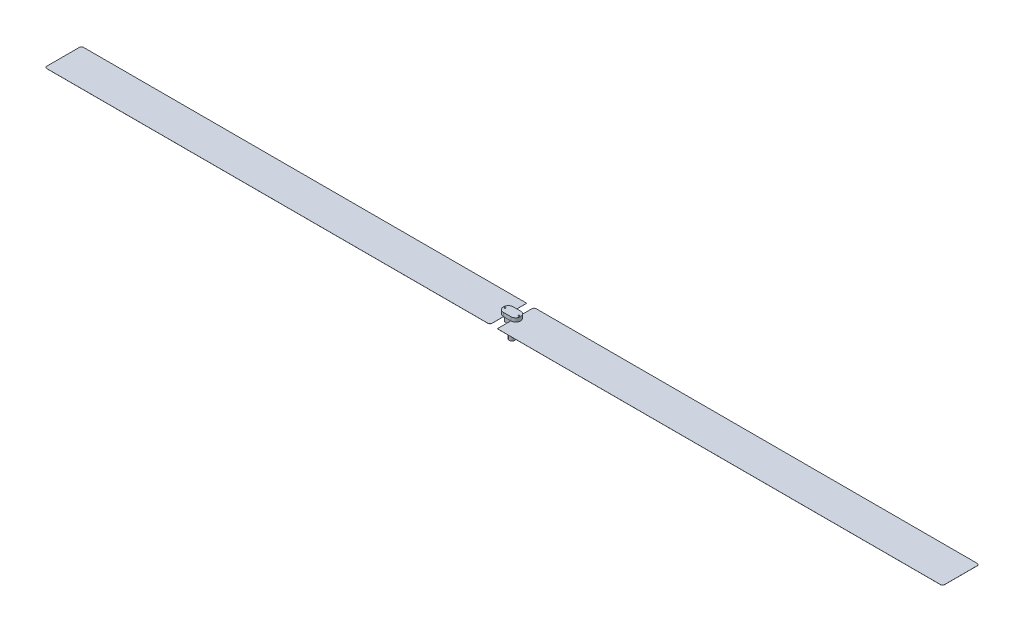
from build123d import *

# Parameters (mm, degrees)
SKETCH1_R           = 0.37702405
SKETCH1_R_2         = 0.3
BOSS_EXTRUDE1_DEPTH = 2
SKETCH2_W           = 1
SKETCH2_H           = 1
BOSS_EXTRUDE2_DEPTH = 0.7
BOSS_EXTRUDE3_DEPTH = 0.5
SKETCH4_R           = 0.1
CUT_EXTRUDE2_DEPTH  = 0.4
BOSS_EXTRUDE4_DEPTH = 0.01


with BuildPart() as part:
    # Sketch1 → Boss-Extrude1 (new body)
    with BuildSketch(Plane(origin=(0, 0, 0), x_dir=(1, 0, 0), z_dir=(0, 1, 0))):
        Circle(SKETCH1_R)
        Circle(SKETCH1_R_2, mode=Mode.SUBTRACT)
    extrude(amount=BOSS_EXTRUDE1_DEPTH)

    # Sketch2 → Boss-Extrude2 (add)
    with BuildSketch(Plane(origin=(0, 2, 0), x_dir=(1, 0, 0), z_dir=(0, 1, 0))):
        Rectangle(SKETCH2_W, SKETCH2_H)
    extrude(amount=BOSS_EXTRUDE2_DEPTH)

    # Sketch3 → Boss-Extrude3 (add)
    with BuildSketch(Plane(origin=(0, 2.7, 0), x_dir=(1, 0, 0), z_dir=(0, 1, 0))):
        with BuildLine():
            Line((-0.5, 0.662390112), (0.5, 0.662390112))
            ThreePointArc((0.5, 0.662390112), (1.162390112, 0), (0.5, -0.662390112))
            Line((0.5, -0.662390112), (-0.5, -0.662390112))
            ThreePointArc((-0.5, -0.662390112), (-1.162390112, 0), (-0.5, 0.662390112))
        make_face()
    extrude(amount=BOSS_EXTRUDE3_DEPTH)

    # Sketch4 → Cut-Extrude2 (cut)
    with BuildSketch(Plane(origin=(0, 3.2, 0), x_dir=(1, 0, 0), z_dir=(0, 1, 0))):
        with Locations((-0.941559445, 0)):
            Circle(SKETCH4_R)
        with Locations((0.941559445, 0)):
            Circle(SKETCH4_R)
    extrude(amount=-CUT_EXTRUDE2_DEPTH, mode=Mode.SUBTRACT)

    # Sketch5 → Boss-Extrude4 (add)
    with BuildSketch(Plane.XZ.offset(-2.7)):
        with BuildLine():
            Line((0.8, -2.5), (60.8, -2.5))
            ThreePointArc((60.8, -2.5), (61.012132034, -2.412132034), (61.1, -2.2))
            Line((61.1, -2.2), (61.1, 2.2))
            ThreePointArc((61.1, 2.2), (61.012132034, 2.412132034), (60.8, 2.5))
            Line((60.8, 2.5), (0.5, 2.5))
            Line((0.5, 2.5), (0.5, -2.2))
            ThreePointArc((0.5, -2.2), (0.587867966, -2.412132034), (0.8, -2.5))
        make_face()
        with BuildLine():
            Line((-0.8, 2.5), (-60.8, 2.5))
            ThreePointArc((-60.8, 2.5), (-61.012132034, 2.412132034), (-61.1, 2.2))
            Line((-61.1, 2.2), (-61.1, -2.2))
            ThreePointArc((-61.1, -2.2), (-61.012132034, -2.412132034), (-60.8, -2.5))
            Line((-60.8, -2.5), (-0.8, -2.5))
            Line((-0.8, -2.5), (-0.5, -2.5))
            Line((-0.5, -2.5), (-0.5, -2.2))
            Line((-0.5, -2.2), (-0.5, 2.2))
            ThreePointArc((-0.5, 2.2), (-0.587867966, 2.412132034), (-0.8, 2.5))
        make_face()
    extrude(amount=BOSS_EXTRUDE4_DEPTH)


solid = part.part
